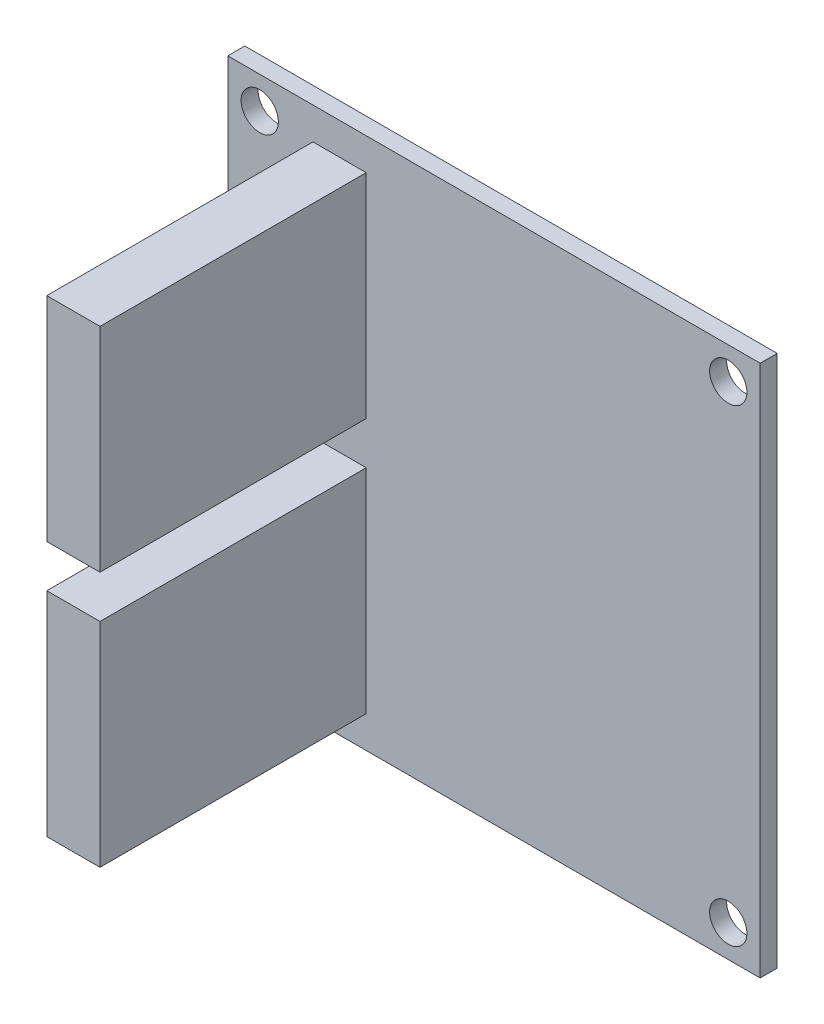
from build123d import *

# Parameters (mm, degrees)
ESQUISSE1_W                  = 50
ESQUISSE1_H                  = 50
BOSS_EXTRU_1_DEPTH           = 1.6
ESQUISSE2_R                  = 1.75
ENL_V_MAT_EXTRU_1_DEPTH      = 1
ENL_V_MAT_EXTRU_1_DEPTH_BACK = 2.6
ESQUISSE3_W                  = 5
ESQUISSE3_H                  = 20
BOSS_EXTRU_2_DEPTH           = 25


with BuildPart() as part:
    # Esquisse1 → Boss.-Extru.1 (new body)
    with BuildSketch(Plane.XY):
        with Locations((25, 25)):
            Rectangle(ESQUISSE1_W, ESQUISSE1_H)
    extrude(amount=BOSS_EXTRU_1_DEPTH)

    # Esquisse2 → Enlèv. mat.-Extru.1 (cut, two sides)
    with BuildSketch(Plane.XY.offset(1.6)) as enl_v_mat_extru_1_sk:
        with Locations((3, 3)):
            Circle(ESQUISSE2_R)
        with Locations((47, 3)):
            Circle(ESQUISSE2_R)
        with Locations((47, 47)):
            Circle(ESQUISSE2_R)
        with Locations((3, 47)):
            Circle(ESQUISSE2_R)
    extrude(amount=ENL_V_MAT_EXTRU_1_DEPTH, mode=Mode.SUBTRACT)
    extrude(enl_v_mat_extru_1_sk.sketch, amount=-ENL_V_MAT_EXTRU_1_DEPTH_BACK, mode=Mode.SUBTRACT)

    # Esquisse3 → Boss.-Extru.2 (add)
    with BuildSketch(Plane.XY.offset(1.6)):
        with Locations((10.5, 37)):
            Rectangle(ESQUISSE3_W, ESQUISSE3_H)
        with Locations((10.5, 13)):
            Rectangle(ESQUISSE3_W, ESQUISSE3_H)
    extrude(amount=BOSS_EXTRU_2_DEPTH)


solid = part.part
